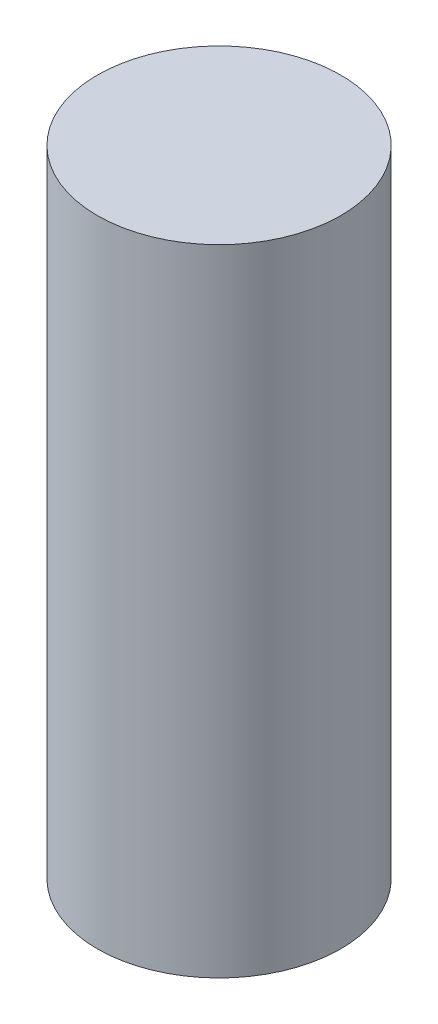
from build123d import *

# Parameters (mm, degrees)
SKETCH1_R           = 2.875
BOSS_EXTRUDE1_DEPTH = 15


with BuildPart() as part:
    # Sketch1 → Boss-Extrude1 (new body)
    with BuildSketch(Plane(origin=(0, 0, 0), x_dir=(1, 0, 0), z_dir=(0, 1, 0))):
        Circle(SKETCH1_R)
    extrude(amount=BOSS_EXTRUDE1_DEPTH)


solid = part.part
